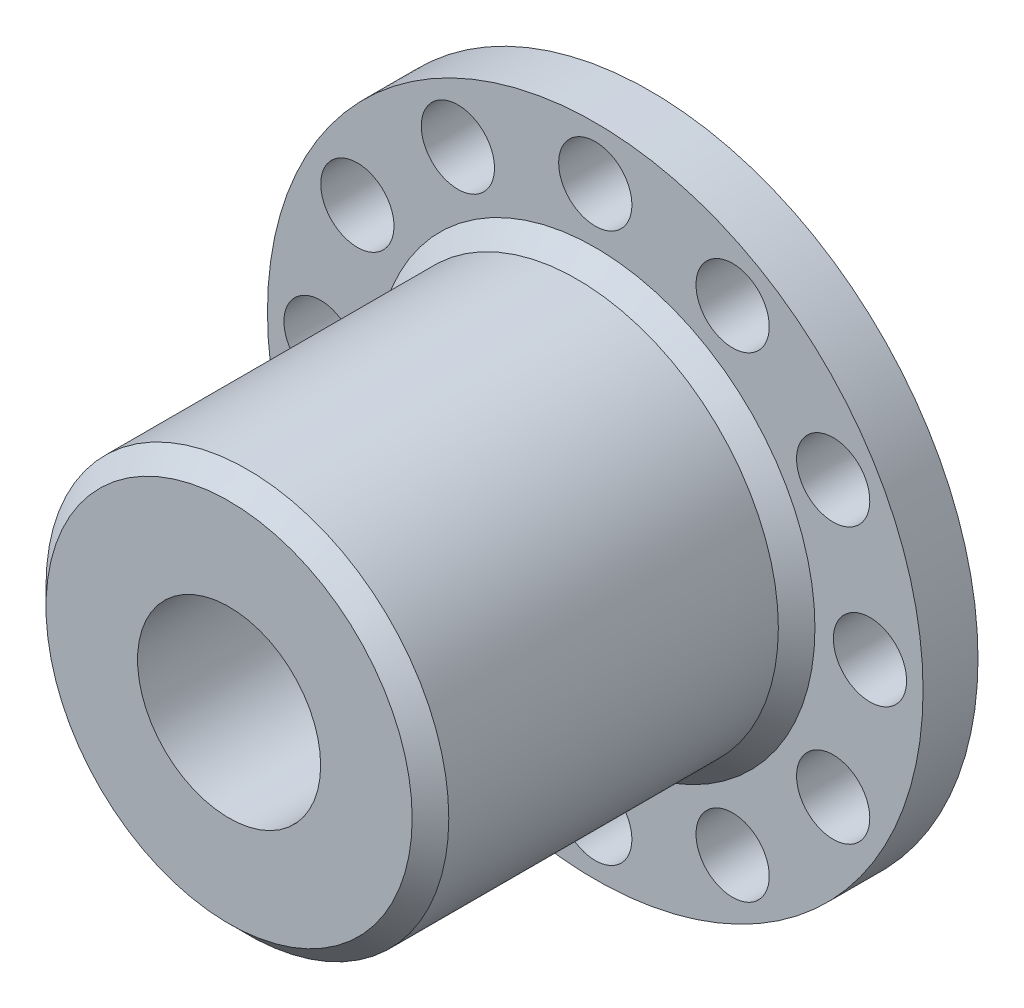
from build123d import *

# Parameters (mm, degrees)
SKETCH1_R           = 17.904347826
BOSS_EXTRUDE1_DEPTH = 3
SKETCH2_R           = 11
BOSS_EXTRUDE2_DEPTH = 20
SKETCH3_R           = 5
CUT_EXTRUDE1_DEPTH  = 24
SKETCH4_R           = 2
CUT_EXTRUDE2_DEPTH  = 15
CHAMFER1_SIZE       = 1
SKETCH5_R           = 2
CUT_EXTRUDE5_DEPTH  = 4.0000001
CIRPATTERN2_COUNT   = 12
SCALE1_SCALE        = 0.630434783


with BuildPart() as part:
    # Sketch1 → Boss-Extrude1 (new body)
    with BuildSketch(Plane.XY):
        Circle(SKETCH1_R)
    extrude(amount=BOSS_EXTRUDE1_DEPTH)

    # Sketch2 → Boss-Extrude2 (add)
    with BuildSketch(Plane.XY.offset(3)):
        Circle(SKETCH2_R)
    extrude(amount=BOSS_EXTRUDE2_DEPTH)

    # Sketch3 → Cut-Extrude1 (cut, through all)
    with BuildSketch(Plane.XY.offset(23)):
        Circle(SKETCH3_R)
    extrude(amount=-CUT_EXTRUDE1_DEPTH, mode=Mode.SUBTRACT)

    # Sketch4 → Cut-Extrude2 (cut)
    with BuildSketch(Plane(origin=(0, 0, 0), x_dir=(1, 0, 0), z_dir=(0, 1, 0))):
        with Locations((0, -15)):
            Circle(SKETCH4_R)
    extrude(amount=-CUT_EXTRUDE2_DEPTH, mode=Mode.SUBTRACT)

    # Chamfer1
    chamfer1_edges = [part.edges().sort_by_distance(p)[0] for p in [
        (-11, 0, 3),
        (-11, 0, 23),
    ]]
    chamfer(chamfer1_edges, length=CHAMFER1_SIZE)

    # Sketch5 → Cut-Extrude5 (cut, through all)
    with BuildSketch(Plane.XY.offset(3)):
        with Locations((7.502173913, 12.994146385)):
            Circle(SKETCH5_R)
    cut_extrude5 = extrude(amount=-CUT_EXTRUDE5_DEPTH, mode=Mode.SUBTRACT)

    # CirPattern2: Cut-Extrude5 ×12 about axis
    cirpattern2_axis = Axis((0, 0, 0), (0, 0, 1))
    for i in range(1, CIRPATTERN2_COUNT):
        add(cut_extrude5.rotate(cirpattern2_axis, i * 360 / CIRPATTERN2_COUNT), mode=Mode.SUBTRACT)


with BuildPart() as part_1:
    # Scale1: scaled about (0, 0, 0)
    add(part.part.scale(SCALE1_SCALE))


solid = part_1.part
